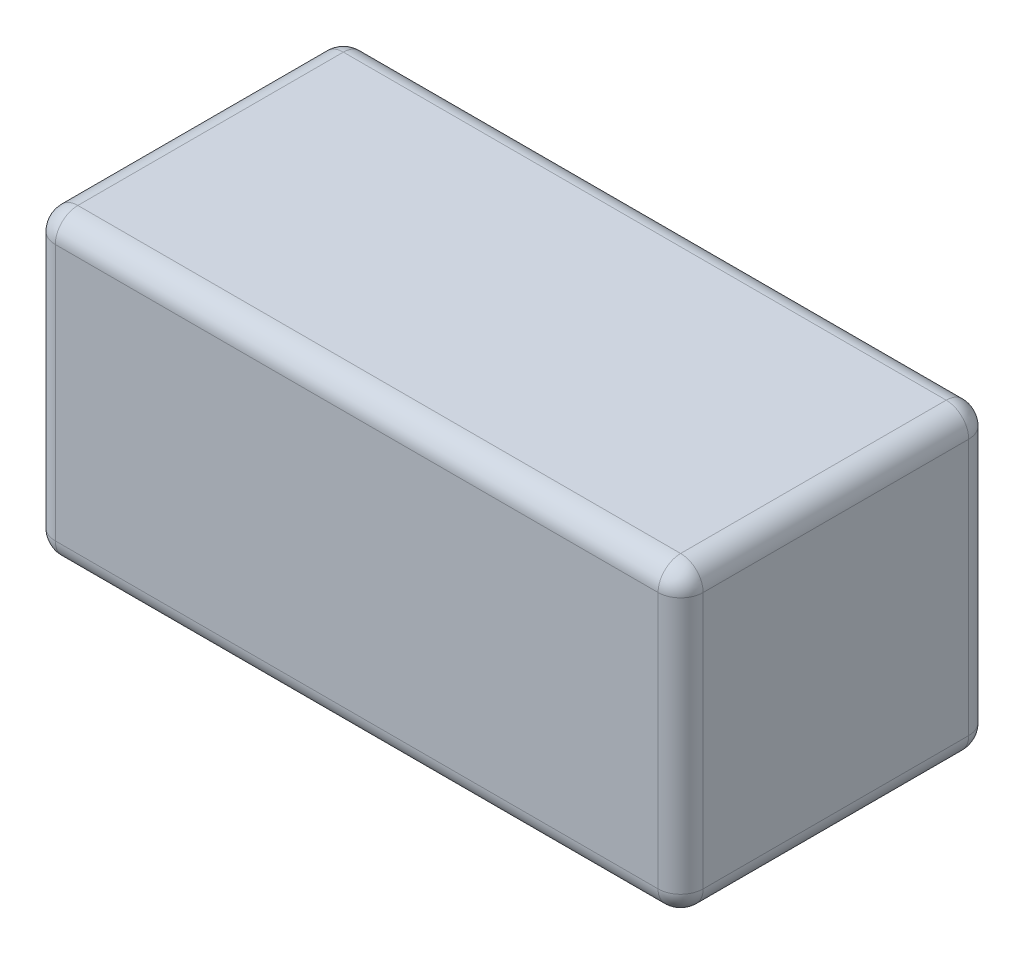
from build123d import *

# Parameters (mm, degrees)
SKETCH1_W           = 73
SKETCH1_H           = 34
BOSS_EXTRUDE1_DEPTH = 35
FILLET1_R           = 2.54


with BuildPart() as part:
    # Sketch1 → Boss-Extrude1 (new body)
    with BuildSketch(Plane.XY):
        Rectangle(SKETCH1_W, SKETCH1_H)
    extrude(amount=BOSS_EXTRUDE1_DEPTH)

    # Fillet1
    fillet1_edges = [part.edges().sort_by_distance(p)[0] for p in [
        (36.5, 0, 35),
        (0, 17, 35),
        (-36.5, 0, 35),
        (0, 17, 0),
        (36.5, 0, 0),
        (0, -17, 0),
        (-36.5, 0, 0),
        (0, -17, 35),
        (-36.5, 17, 17.5),
        (36.5, 17, 17.5),
        (36.5, -17, 17.5),
        (-36.5, -17, 17.5),
    ]]
    fillet(fillet1_edges, radius=FILLET1_R)


solid = part.part
